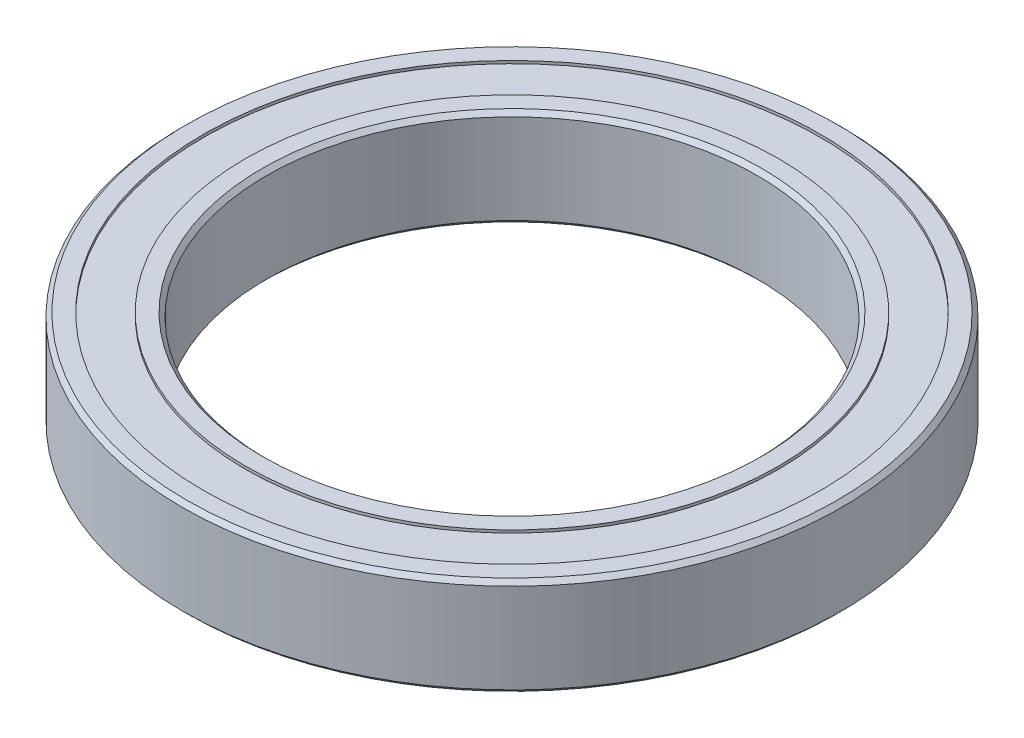
from build123d import *

# Parameters (mm, degrees)
SKETCH1_R           = 23.5
SKETCH1_R_2         = 17.5
BOSS_EXTRUDE1_DEPTH = 7
SKETCH2_R           = 22
SKETCH2_R_2         = 19
CUT_EXTRUDE1_DEPTH  = 0.2
CHAMFER1_SIZE       = 0.3
SKETCH3_R           = 22
SKETCH3_R_2         = 19
CUT_EXTRUDE2_DEPTH  = 0.2


with BuildPart() as part:
    # Sketch1 → Boss-Extrude1 (new body)
    with BuildSketch(Plane(origin=(0, 0, 0), x_dir=(1, 0, 0), z_dir=(0, 1, 0))):
        Circle(SKETCH1_R)
        Circle(SKETCH1_R_2, mode=Mode.SUBTRACT)
    extrude(amount=BOSS_EXTRUDE1_DEPTH)

    # Sketch2 → Cut-Extrude1 (cut)
    with BuildSketch(Plane(origin=(0, 7, 0), x_dir=(1, 0, 0), z_dir=(0, 1, 0))):
        Circle(SKETCH2_R)
        Circle(SKETCH2_R_2, mode=Mode.SUBTRACT)
    extrude(amount=-CUT_EXTRUDE1_DEPTH, mode=Mode.SUBTRACT)

    # Chamfer1
    chamfer1_edges = [part.edges().sort_by_distance(p)[0] for p in [
        (-23.5, 0, 0),
        (-23.5, 7, 0),
        (-17.5, 0, 0),
        (-17.5, 7, 0),
    ]]
    chamfer(chamfer1_edges, length=CHAMFER1_SIZE)

    # Sketch3 → Cut-Extrude2 (cut)
    with BuildSketch(Plane.XZ):
        Circle(SKETCH3_R)
        Circle(SKETCH3_R_2, mode=Mode.SUBTRACT)
    extrude(amount=-CUT_EXTRUDE2_DEPTH, mode=Mode.SUBTRACT)


solid = part.part
